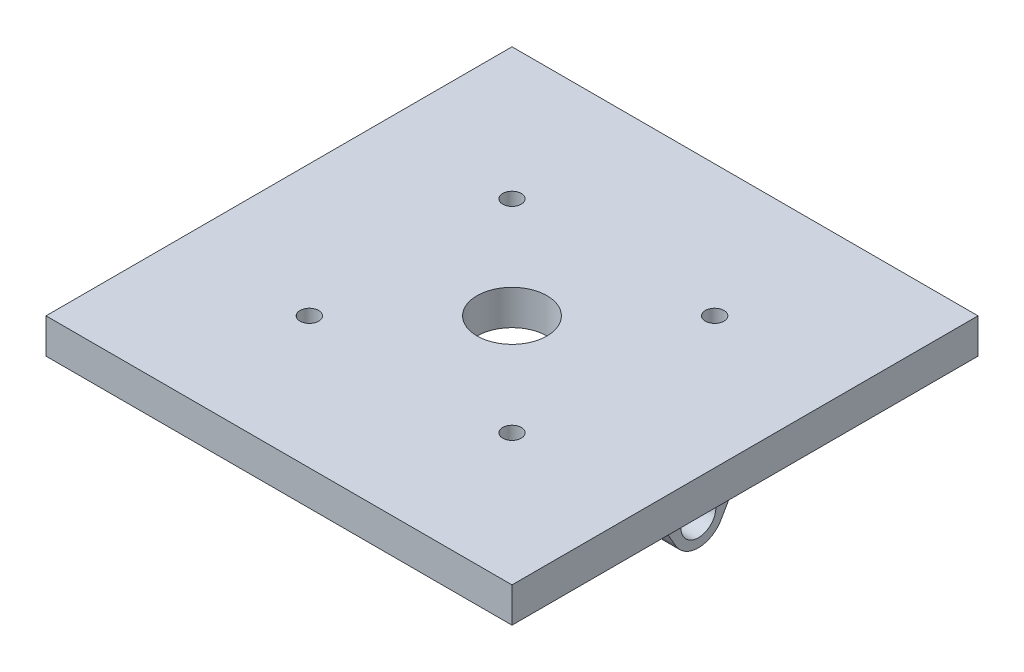
from build123d import *

# Parameters (mm, degrees)
ESBO_O1_W                = 400
ESBO_O1_H                = 400
ESBO_O1_R                = 30
RESSALTO_EXTRUS_O1_DEPTH = 30
RESSALTO_EXTRUS_O2_START = 130
ESBO_O2_R                = 15
RESSALTO_EXTRUS_O2_DEPTH = 30
ESBO_O3_R                = 8
CORTE_EXTRUS_O1_DEPTH    = 93.5


with BuildPart() as part:
    # Esboço1 → Ressalto-extrusão1 (new body)
    with BuildSketch(Plane(origin=(0, 0, 0), x_dir=(1, 0, 0), z_dir=(0, 1, 0))):
        Rectangle(ESBO_O1_W, ESBO_O1_H)
        Circle(ESBO_O1_R, mode=Mode.SUBTRACT)
    extrude(amount=RESSALTO_EXTRUS_O1_DEPTH)

    # Esboço2 → Ressalto-extrusão2 (add)
    with BuildSketch(Plane(origin=(0, 0, 0), x_dir=(0, 0, -1), z_dir=(1, 0, 0)).offset(RESSALTO_EXTRUS_O2_START)):
        with BuildLine():
            Line((-19.485571585, -51.25), (-44.744645862, -7.5))
            ThreePointArc((-44.744645862, -7.5), (-50.235026919, -2.009618943), (-57.735026919, 0))
            Line((-57.735026919, 0), (57.735026919, 0))
            ThreePointArc((57.735026919, 0), (50.235026919, -2.009618943), (44.744645862, -7.5))
            Line((44.744645862, -7.5), (19.485571585, -51.25))
            ThreePointArc((19.485571585, -51.25), (0, -62.5), (-19.485571585, -51.25))
        make_face()
        with Locations((0, -40)):
            Circle(ESBO_O2_R, mode=Mode.SUBTRACT)
    ressalto_extrus_o2 = extrude(amount=RESSALTO_EXTRUS_O2_DEPTH)

    # Espelhar1: Ressalto-extrusão2 across plane
    add(ressalto_extrus_o2.mirror(Plane(origin=(0, 0, 0), x_dir=(0, 0, 1), z_dir=(1, 0, 0))))

    # Esboço3 → Corte-extrusão1 (cut, through all)
    with BuildSketch(Plane(origin=(0, 30, 0), x_dir=(1, 0, 0), z_dir=(0, 1, 0))):
        with Locations((-86.974, 86.974)):
            Circle(ESBO_O3_R)
        with Locations((86.974, 86.974)):
            Circle(ESBO_O3_R)
        with Locations((86.974, -86.974)):
            Circle(ESBO_O3_R)
        with Locations((-86.974, -86.974)):
            Circle(ESBO_O3_R)
    extrude(amount=-CORTE_EXTRUS_O1_DEPTH, mode=Mode.SUBTRACT)


solid = part.part
